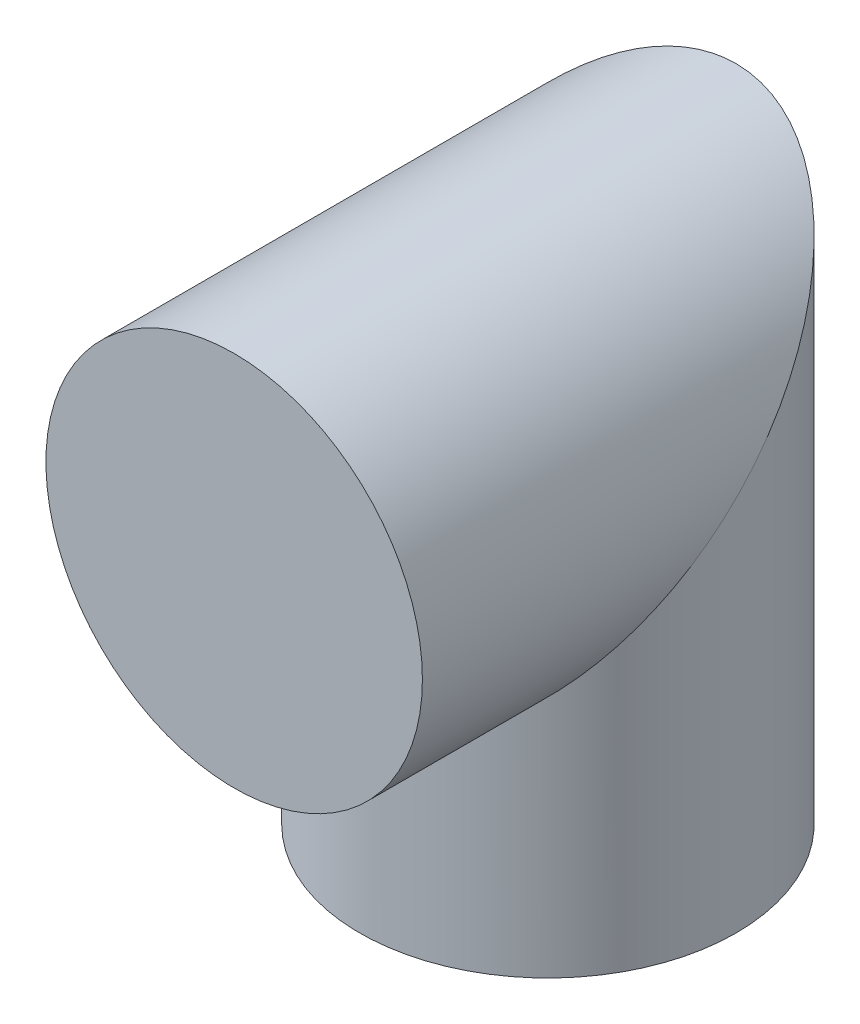
from build123d import *

# Parameters (mm, degrees)
SKETCH3_R = 30


with BuildPart() as part:
    # Sweep1: sweep along a path in Sketch1
    with BuildLine(Plane(origin=(0, 0, 0), x_dir=(0, 0, -1), z_dir=(1, 0, 0))) as sweep1_path:
        Line((0, 0), (50, 0))
        Line((50, 0), (50, -60))
    # Sketch3 → Sweep1 (sweep)
    with BuildSketch(Plane.XY):
        Circle(SKETCH3_R)
    sweep(path=sweep1_path.line, transition=Transition.RIGHT)


solid = part.part
